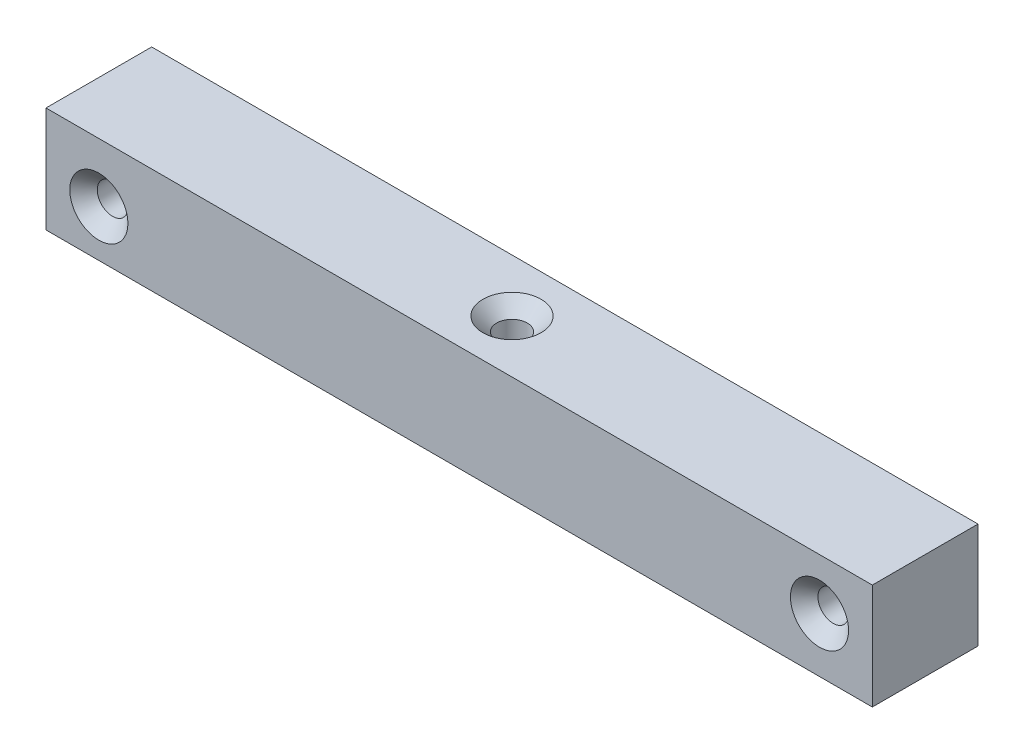
from build123d import *

# Parameters (mm, degrees)
SKETCH1_W                                         = 78.2
SKETCH1_H                                         = 10
BOSS_EXTRUDE1_DEPTH                               = 10
CSK_FOR_M2_5_FLAT_HEAD_MACHINE_SCREW1_D           = 2.9
CSK_FOR_M2_5_FLAT_HEAD_MACHINE_SCREW1_CSINK_D     = 5.5
CSK_FOR_M2_5_FLAT_HEAD_MACHINE_SCREW1_CSINK_ANGLE = 90
CSK_FOR_M2_5_FLAT_HEAD_MACHINE_SCREW2_D           = 2.9
CSK_FOR_M2_5_FLAT_HEAD_MACHINE_SCREW2_CSINK_D     = 5.5
CSK_FOR_M2_5_FLAT_HEAD_MACHINE_SCREW2_CSINK_ANGLE = 90
CSK_FOR_M2_5_FLAT_HEAD_MACHINE_SCREW3_D           = 2.9
CSK_FOR_M2_5_FLAT_HEAD_MACHINE_SCREW3_CSINK_D     = 5.5
CSK_FOR_M2_5_FLAT_HEAD_MACHINE_SCREW3_CSINK_ANGLE = 90


with BuildPart() as part:
    # Sketch1 → Boss-Extrude1 (new body)
    with BuildSketch(Plane(origin=(0, 0, 0), x_dir=(1, 0, 0), z_dir=(0, 1, 0))):
        with Locations((-39.1, -5)):
            Rectangle(SKETCH1_W, SKETCH1_H)
    extrude(amount=BOSS_EXTRUDE1_DEPTH)

    # CSK for M2.5 Flat Head Machine Screw1 (through all)
    with Locations(Plane.XY.offset(10)):
        with Locations((-5, 5.154214905)):
            CounterSinkHole(CSK_FOR_M2_5_FLAT_HEAD_MACHINE_SCREW1_D / 2, CSK_FOR_M2_5_FLAT_HEAD_MACHINE_SCREW1_CSINK_D / 2, counter_sink_angle=CSK_FOR_M2_5_FLAT_HEAD_MACHINE_SCREW1_CSINK_ANGLE)

    # CSK for M2.5 Flat Head Machine Screw2 (through all)
    with Locations(Plane.XY.offset(10)):
        with Locations((-73.199, 4.414547578)):
            CounterSinkHole(CSK_FOR_M2_5_FLAT_HEAD_MACHINE_SCREW2_D / 2, CSK_FOR_M2_5_FLAT_HEAD_MACHINE_SCREW2_CSINK_D / 2, counter_sink_angle=CSK_FOR_M2_5_FLAT_HEAD_MACHINE_SCREW2_CSINK_ANGLE)

    # CSK for M2.5 Flat Head Machine Screw3 (through all)
    with Locations(Plane(origin=(0, 10, 0), x_dir=(1, 0, 0), z_dir=(0, 1, 0))):
        with Locations((-39.1, -5)):
            CounterSinkHole(CSK_FOR_M2_5_FLAT_HEAD_MACHINE_SCREW3_D / 2, CSK_FOR_M2_5_FLAT_HEAD_MACHINE_SCREW3_CSINK_D / 2, counter_sink_angle=CSK_FOR_M2_5_FLAT_HEAD_MACHINE_SCREW3_CSINK_ANGLE)


solid = part.part
